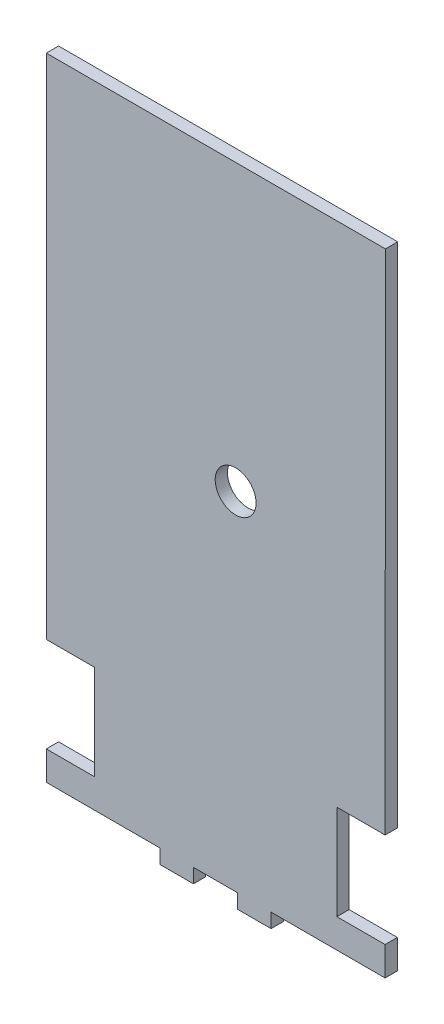
from build123d import *

# Parameters (mm, degrees)
MODEL_R                 = 5
SALIENTE_EXTRUIR1_DEPTH = 3


with BuildPart() as part:
    # Model → Saliente-Extruir1 (new body)
    with BuildSketch(Plane.XY):
        Polygon((-6.252169072, 97.692435924), (-6.252193556, -12.992273376), (-6.252189787, -26.569876975), (5.547810863, -26.569876975), (5.547810863, -49.769877975), (-6.252190137, -49.769877975), (-6.252190137, -56.854616562), (21.555168443, -56.868689524), (21.555168443, -60.362222872), (29.755168443, -60.362222872), (29.755168443, -56.862222872), (40.555168443, -56.862222872), (40.555168443, -60.362222872), (48.755168443, -60.362222872), (48.755168443, -56.862222872), (76.65518199, -56.869876074), (76.65518199, -49.769878074), (64.85518199, -49.769878074), (64.85518199, -26.569877074), (76.65518199, -26.569877074), (76.747833538, 97.692420221), align=None)
        with Locations((40.085557046, 27.970559754)):
            Circle(MODEL_R, mode=Mode.SUBTRACT)
    extrude(amount=SALIENTE_EXTRUIR1_DEPTH)


solid = part.part
